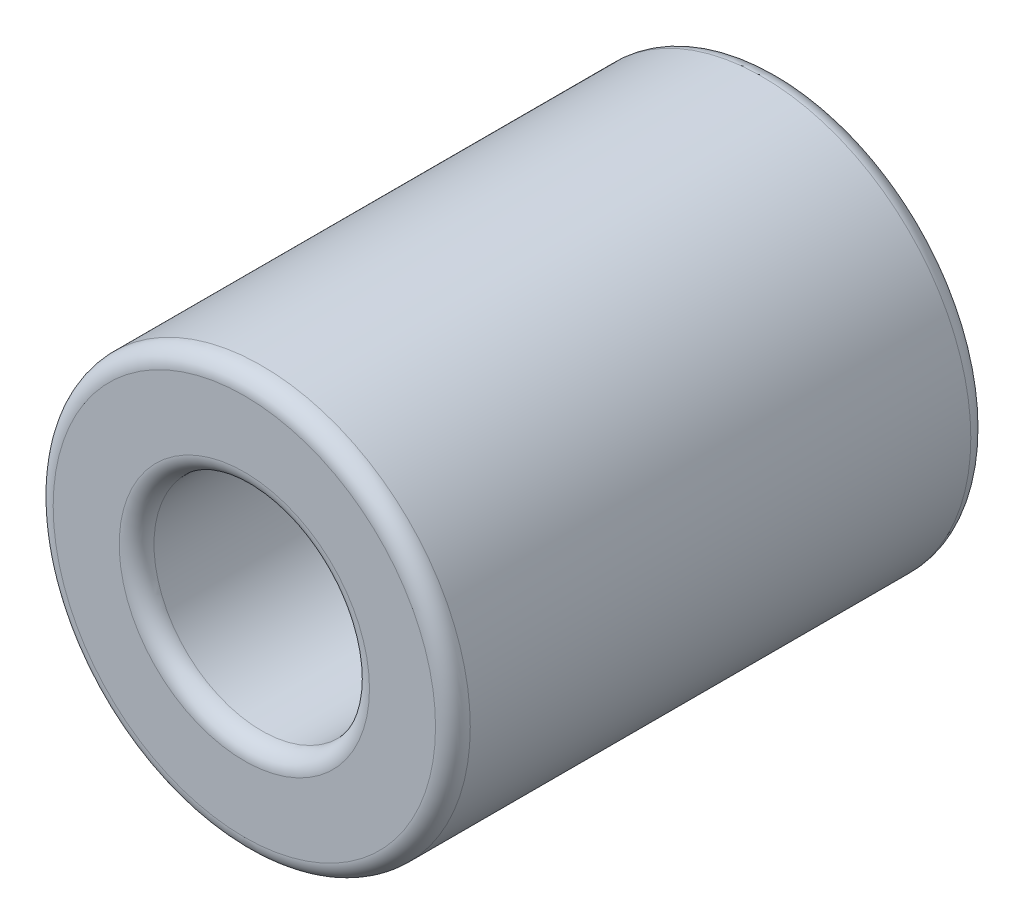
from build123d import *

# Parameters (mm, degrees)
SKICA2_R                = 3
SKICA2_R_2              = 1.55
P_IDAT_VYSUNUT_M1_DEPTH = 7.7
ZAOBLIT1_R              = 0.25


with BuildPart() as part:
    # Skica2 → Přidat vysunutím1 (new body)
    with BuildSketch(Plane.XY):
        Circle(SKICA2_R)
        Circle(SKICA2_R_2, mode=Mode.SUBTRACT)
    extrude(amount=P_IDAT_VYSUNUT_M1_DEPTH)

    # Zaoblit1
    zaoblit1_edges = [part.edges().sort_by_distance(p)[0] for p in [
        (-3, 0, 0),
        (-3, 0, 7.7),
        (-1.55, 0, 0),
        (-1.55, 0, 7.7),
    ]]
    fillet(zaoblit1_edges, radius=ZAOBLIT1_R)


solid = part.part
